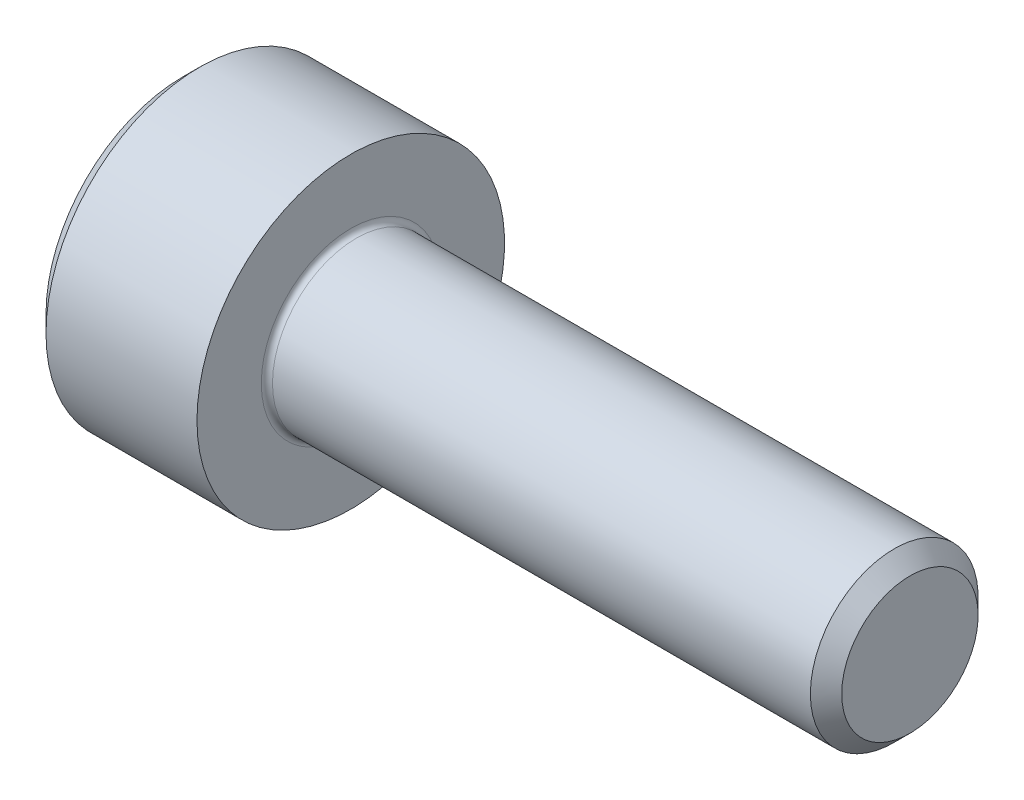
from build123d import *

# Parameters (mm, degrees)
FILLET1_R   = 0.1
HEX_2_DEPTH = 1.3


with BuildPart() as part:
    # BodySke → Base-Revolve (revolve)
    with BuildSketch(Plane.XY):
        Polygon((0, 0), (0, 2.45), (0.3, 2.75), (3, 2.75), (3, 1.5), (12.7195, 1.5), (13, 1.2195), (13, 0), align=None)
    revolve(axis=Axis((-31.75, 0, 0), (1, 0, 0)))

    # Fillet1
    fillet1_edges = [part.edges().sort_by_distance(p)[0] for p in [
        (3, -1.5, 0),
    ]]
    fillet(fillet1_edges, radius=FILLET1_R)

    # Sketch2 → Hex-PreBroach (revolve, cut)
    with BuildSketch(Plane.XY):
        Polygon((0, 1.28), (1.3, 1.28), (2.039008345, 0), (0, 0), align=None)
    revolve(axis=Axis((0, 0, 0), (1, 0, 0)), mode=Mode.SUBTRACT)

    # Sketch3 → Hex 2 (cut)
    with BuildSketch(Plane(origin=(0, 0, 0), x_dir=(0, 0.5, 0.866025404), z_dir=(-1, 0, 0))):
        Polygon((0.739008345, 1.28), (-0.739008345, 1.28), (-1.478016689, 0), (-0.739008345, -1.28), (0.739008345, -1.28), (1.478016689, 0), align=None)
    extrude(amount=-HEX_2_DEPTH, mode=Mode.SUBTRACT)


solid = part.part
